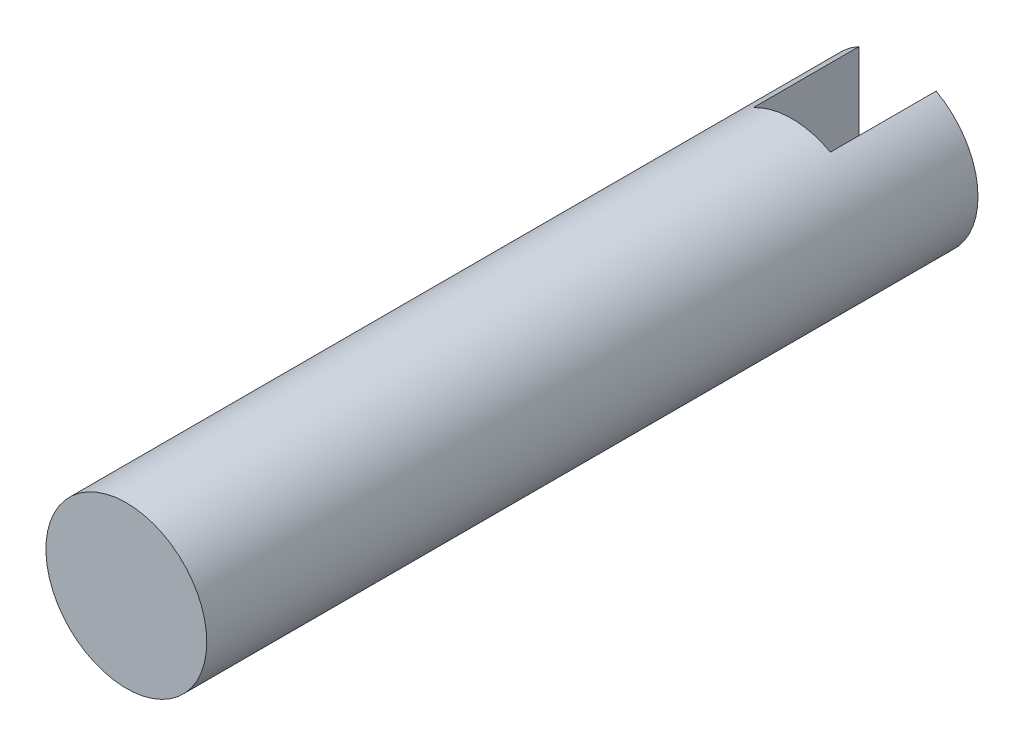
from build123d import *

# Parameters (mm, degrees)
ESQUISSE1_R             = 3.65
BOSS_EXTRU_1_DEPTH      = 35
ENL_V_MAT_EXTRU_1_DEPTH = 4.8


with BuildPart() as part:
    # Esquisse1 → Boss.-Extru.1 (new body)
    with BuildSketch(Plane.XY):
        Circle(ESQUISSE1_R)
    extrude(amount=BOSS_EXTRU_1_DEPTH)

    # Esquisse2 → Enlèv. mat.-Extru.1 (cut)
    with BuildSketch(Plane(origin=(0, 0, 0), x_dir=(-1, 0, 0), z_dir=(0, 0, -1))):
        with BuildLine():
            Line((1.75, 4), (1.75, -4))
            ThreePointArc((1.75, -4), (0, -5.75), (-1.75, -4))
            Line((-1.75, -4), (-1.75, 4))
            ThreePointArc((-1.75, 4), (0, 5.75), (1.75, 4))
        make_face()
    extrude(amount=-ENL_V_MAT_EXTRU_1_DEPTH, mode=Mode.SUBTRACT)


solid = part.part
